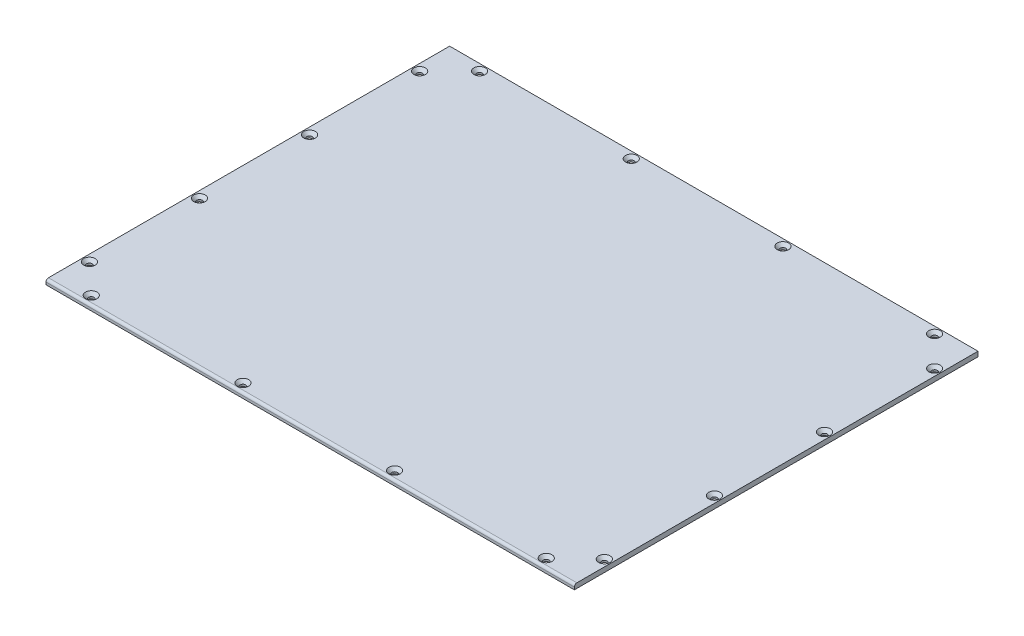
from build123d import *

# Parameters (mm, degrees)
SKETCH_2_W                 = 432
SKETCH_2_H                 = 330
EXTRUDE_1_DEPTH            = 4
FILLET_1_R                 = 2
HOLE_WIZARD_M4_AT_2_COUNT  = 2
HOLE_WIZARD_M4_AT_2_PITCH  = 124
HOLE_WIZARD_M4_AT_3_COUNT  = 2
HOLE_WIZARD_M4_AT_3_PITCH  = 248
HOLE_WIZARD_M4_AT_4_COUNT  = 2
HOLE_WIZARD_M4_AT_4_PITCH  = 372
HOLE_WIZARD_M4_AT_5_COUNT  = 2
HOLE_WIZARD_M4_AT_5_PITCH  = 397.256214552
HOLE_WIZARD_M4_AT_6_COUNT  = 2
HOLE_WIZARD_M4_AT_6_PITCH  = 412.701465953
HOLE_WIZARD_M4_AT_7_COUNT  = 2
HOLE_WIZARD_M4_AT_7_PITCH  = 446.130586264
HOLE_WIZARD_M4_AT_8_COUNT  = 2
HOLE_WIZARD_M4_AT_8_PITCH  = 493.905355306
HOLE_WIZARD_M4_AT_9_COUNT  = 2
HOLE_WIZARD_M4_AT_9_PITCH  = 489.070802645
HOLE_WIZARD_M4_AT_10_COUNT = 2
HOLE_WIZARD_M4_AT_10_PITCH = 402.87746276
HOLE_WIZARD_M4_AT_11_COUNT = 2
HOLE_WIZARD_M4_AT_11_PITCH = 340.855174524
HOLE_WIZARD_M4_AT_12_COUNT = 2
HOLE_WIZARD_M4_AT_12_PITCH = 317.5
HOLE_WIZARD_M4_AT_13_COUNT = 2
HOLE_WIZARD_M4_AT_13_PITCH = 295.517342977
HOLE_WIZARD_M4_AT_14_COUNT = 2
HOLE_WIZARD_M4_AT_14_PITCH = 205.962375205
HOLE_WIZARD_M4_AT_15_COUNT = 2
HOLE_WIZARD_M4_AT_15_PITCH = 117.091844293
HOLE_WIZARD_M4_AT_16_COUNT = 2
HOLE_WIZARD_M4_AT_16_PITCH = 34.648232278


with BuildPart() as part:
    # 草圖2 → 填料-伸長1 (new body)
    with BuildSketch(Plane(origin=(0, 0, 0), x_dir=(1, 0, 0), z_dir=(0, 1, 0))):
        with Locations((216, 165)):
            Rectangle(SKETCH_2_W, SKETCH_2_H)
    extrude(amount=EXTRUDE_1_DEPTH)

    # 圓角1
    fillet_1_edges = [part.edges().sort_by_distance(p)[0] for p in [
        (216, 4, 0),
    ]]
    fillet(fillet_1_edges, radius=FILLET_1_R)

    # 草圖4 → M4 測板連接 (revolve, cut)
    with BuildSketch(Plane(origin=(30, 4, -324.5), x_dir=(0, 0, 1), z_dir=(1, 0, 0))):
        Polygon((0, 0), (0, 4), (2.25, 4), (2.25, 2.45), (4.7, 0), align=None)
    hole_wizard_m4 = revolve(axis=Axis((30, 10.35, -324.5), (0, -1, 0)), mode=Mode.SUBTRACT)

    # M4 測板連接 at 2: M4 測板連接 ×2
    with Locations(*[(i * HOLE_WIZARD_M4_AT_2_PITCH, 0, 0) for i in range(1, HOLE_WIZARD_M4_AT_2_COUNT)]):
        add(hole_wizard_m4, mode=Mode.SUBTRACT)

    # M4 測板連接 at 3: M4 測板連接 ×2
    with Locations(*[(i * HOLE_WIZARD_M4_AT_3_PITCH, 0, 0) for i in range(1, HOLE_WIZARD_M4_AT_3_COUNT)]):
        add(hole_wizard_m4, mode=Mode.SUBTRACT)

    # M4 測板連接 at 4: M4 測板連接 ×2
    with Locations(*[(i * HOLE_WIZARD_M4_AT_4_PITCH, 0, 0) for i in range(1, HOLE_WIZARD_M4_AT_4_COUNT)]):
        add(hole_wizard_m4, mode=Mode.SUBTRACT)

    # M4 測板連接 at 5: M4 測板連接 ×2
    with Locations(*[Vector(0.998096406, 0, 0.061673044) * (i * HOLE_WIZARD_M4_AT_5_PITCH) for i in range(1, HOLE_WIZARD_M4_AT_5_COUNT)]):
        add(hole_wizard_m4, mode=Mode.SUBTRACT)

    # M4 測板連接 at 6: M4 測板連接 ×2
    with Locations(*[Vector(0.960742892, 0, 0.277440255) * (i * HOLE_WIZARD_M4_AT_6_PITCH) for i in range(1, HOLE_WIZARD_M4_AT_6_COUNT)]):
        add(hole_wizard_m4, mode=Mode.SUBTRACT)

    # M4 測板連接 at 7: M4 測板連接 ×2
    with Locations(*[Vector(0.888753231, 0, 0.458385967) * (i * HOLE_WIZARD_M4_AT_7_PITCH) for i in range(1, HOLE_WIZARD_M4_AT_7_COUNT)]):
        add(hole_wizard_m4, mode=Mode.SUBTRACT)

    # M4 測板連接 at 8: M4 測板連接 ×2
    with Locations(*[Vector(0.802785383, 0, 0.596268084) * (i * HOLE_WIZARD_M4_AT_8_PITCH) for i in range(1, HOLE_WIZARD_M4_AT_8_COUNT)]):
        add(hole_wizard_m4, mode=Mode.SUBTRACT)

    # M4 測板連接 at 9: M4 測板連接 ×2
    with Locations(*[Vector(0.760626065, 0, 0.649190257) * (i * HOLE_WIZARD_M4_AT_9_PITCH) for i in range(1, HOLE_WIZARD_M4_AT_9_COUNT)]):
        add(hole_wizard_m4, mode=Mode.SUBTRACT)

    # M4 測板連接 at 10: M4 測板連接 ×2
    with Locations(*[Vector(0.615571788, 0, 0.788080817) * (i * HOLE_WIZARD_M4_AT_10_PITCH) for i in range(1, HOLE_WIZARD_M4_AT_10_COUNT)]):
        add(hole_wizard_m4, mode=Mode.SUBTRACT)

    # M4 測板連接 at 11: M4 測板連接 ×2
    with Locations(*[Vector(0.363790869, 0, 0.931480651) * (i * HOLE_WIZARD_M4_AT_11_PITCH) for i in range(1, HOLE_WIZARD_M4_AT_11_COUNT)]):
        add(hole_wizard_m4, mode=Mode.SUBTRACT)

    # M4 測板連接 at 12: M4 測板連接 ×2
    with Locations(*[(0, 0, i * HOLE_WIZARD_M4_AT_12_PITCH) for i in range(1, HOLE_WIZARD_M4_AT_12_COUNT)]):
        add(hole_wizard_m4, mode=Mode.SUBTRACT)

    # M4 測板連接 at 13: M4 測板連接 ×2
    with Locations(*[Vector(-0.082905456, 0, 0.996557417) * (i * HOLE_WIZARD_M4_AT_13_PITCH) for i in range(1, HOLE_WIZARD_M4_AT_13_COUNT)]):
        add(hole_wizard_m4, mode=Mode.SUBTRACT)

    # M4 測板連接 at 14: M4 測板連接 ×2
    with Locations(*[Vector(-0.118953765, 0, 0.992899794) * (i * HOLE_WIZARD_M4_AT_14_PITCH) for i in range(1, HOLE_WIZARD_M4_AT_14_COUNT)]):
        add(hole_wizard_m4, mode=Mode.SUBTRACT)

    # M4 測板連接 at 15: M4 測板連接 ×2
    with Locations(*[Vector(-0.209237459, 0, 0.977864861) * (i * HOLE_WIZARD_M4_AT_15_PITCH) for i in range(1, HOLE_WIZARD_M4_AT_15_COUNT)]):
        add(hole_wizard_m4, mode=Mode.SUBTRACT)

    # M4 測板連接 at 16: M4 測板連接 ×2
    with Locations(*[Vector(-0.707106781, 0, 0.707106781) * (i * HOLE_WIZARD_M4_AT_16_PITCH) for i in range(1, HOLE_WIZARD_M4_AT_16_COUNT)]):
        add(hole_wizard_m4, mode=Mode.SUBTRACT)


solid = part.part
